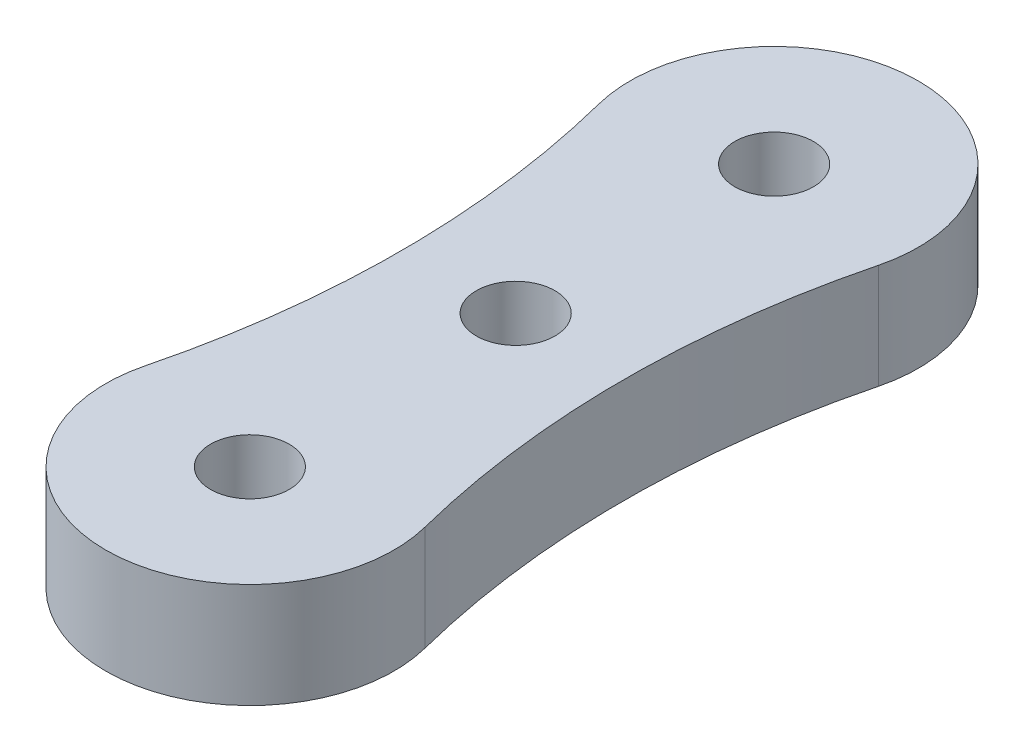
from build123d import *

# Parameters (mm, degrees)
SKETCH1_R           = 1.5
BOSS_EXTRUDE1_DEPTH = 4


with BuildPart() as part:
    # Sketch1 → Boss-Extrude1 (new body)
    with BuildSketch(Plane(origin=(0, 0, 0), x_dir=(1, 0, 0), z_dir=(0, 1, 0))):
        with BuildLine():
            ThreePointArc((-5.330769231, 1.353846154), (0, -5.5), (5.330769231, 1.353846154))
            ThreePointArc((5.330769231, 1.353846154), (4.25, 10), (5.330769231, 18.646153846))
            ThreePointArc((5.330769231, 18.646153846), (0, 25.5), (-5.330769231, 18.646153846))
            ThreePointArc((-5.330769231, 18.646153846), (-4.25, 10), (-5.330769231, 1.353846154))
        make_face()
        Circle(SKETCH1_R, mode=Mode.SUBTRACT)
        with Locations((0, 10.14)):
            Circle(SKETCH1_R, mode=Mode.SUBTRACT)
        with Locations((0, 20)):
            Circle(SKETCH1_R, mode=Mode.SUBTRACT)
    extrude(amount=BOSS_EXTRUDE1_DEPTH)


solid = part.part
